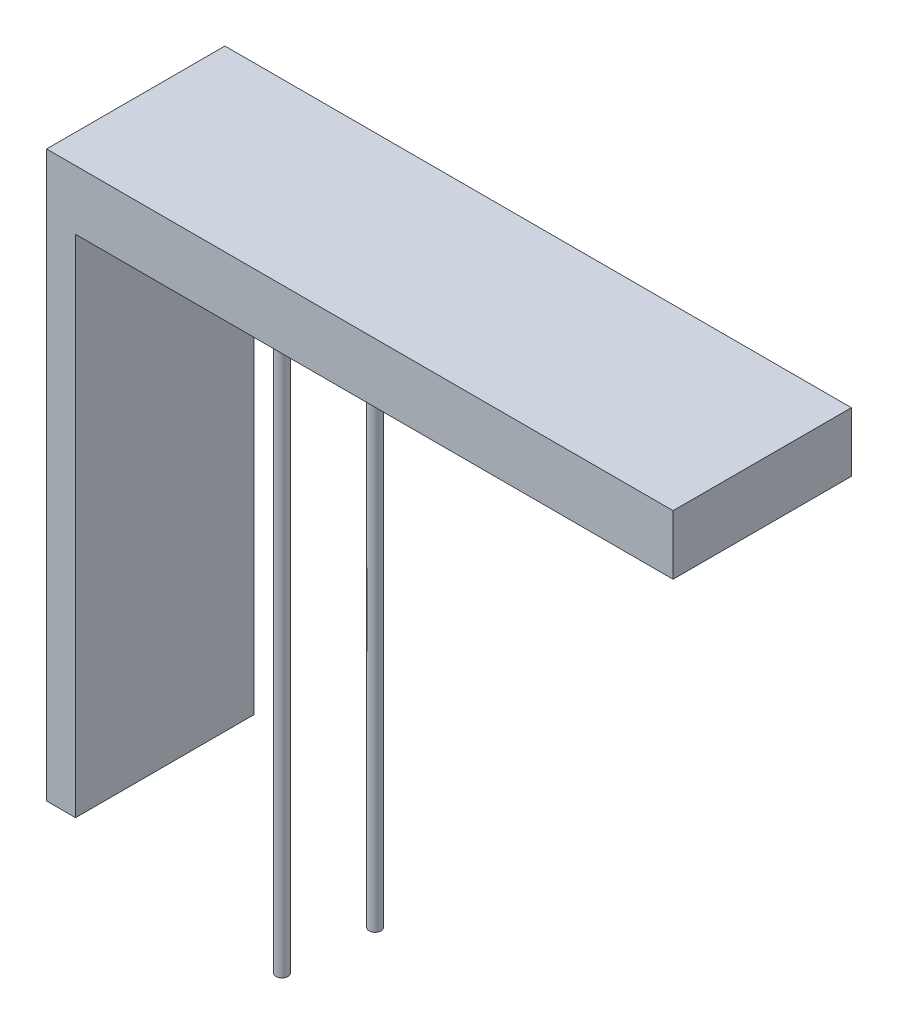
from build123d import *

# Parameters (mm, degrees)
EXTRUSION1_DEPTH = 6
ESQUISSE2_R      = 0.2
EXTRUSION2_DEPTH = 20


with BuildPart() as part:
    # Esquisse1 → Extrusion1 (new body)
    with BuildSketch(Plane.XY):
        Polygon((123.733692342, 14.5), (123.733692342, 31.5), (143.838461576, 31.5), (143.838461576, 33.5), (122.759551823, 33.5), (122.759551823, 14.5), align=None)
    extrude(amount=EXTRUSION1_DEPTH)

    # Esquisse2 → Extrusion2 (add)
    with BuildSketch(Plane.XZ.offset(-31.5)):
        with Locations(Location((128.735391716, 4.056660757, 0), (0, 0, 90))):  # turned: the seam where the file's is
            Circle(ESQUISSE2_R)
        with Locations(Location((128.971557812, 1.159084415, 0), (0, 0, 90))):  # turned: the seam where the file's is
            Circle(ESQUISSE2_R)
    extrude(amount=EXTRUSION2_DEPTH)


solid = part.part
